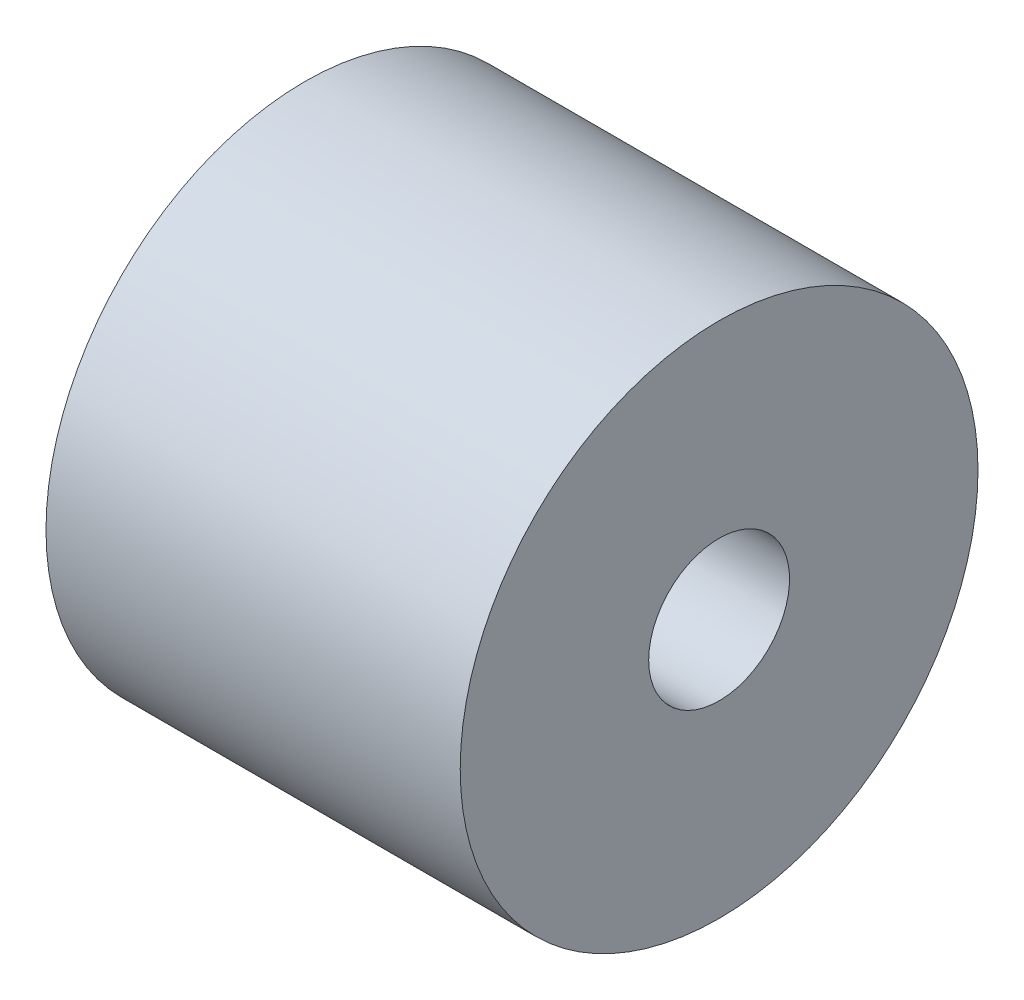
from build123d import *

# Parameters (mm, degrees)
SKETCH_1_W        = 20
SKETCH_1_H        = 12.5
HOLE_WIZARD_M81_D = 6.8


with BuildPart() as part:
    # Эскиз1 → Повернуть1 (revolve)
    with BuildSketch(Plane.XY):
        with Locations((-10, 6.25)):
            Rectangle(SKETCH_1_W, SKETCH_1_H)
    revolve(axis=Axis((-1000, 0, 0), (1, 0, 0)))

    # Отверстие обработанное метчиком M81 (through all)
    with Locations(Plane.ZY.offset(20)):
        with Locations((0, 0)):
            Hole(HOLE_WIZARD_M81_D / 2)


solid = part.part
